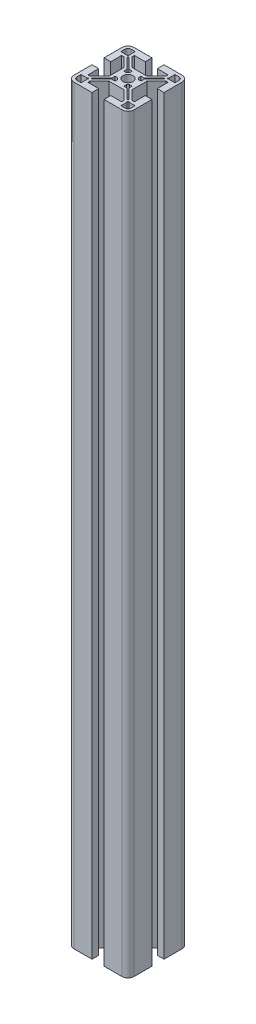
from build123d import *

# Parameters (mm, degrees)
BOSS_EXTRUDE1_DEPTH = 500


with BuildPart() as part:
    # Sketch1 → Boss-Extrude1 (new body)
    with BuildSketch(Plane(origin=(0, 0, 0), x_dir=(1, 0, 0), z_dir=(0, 1, 0))):
        with BuildLine():
            Line((-27.932618907, -6.859852703), (-27.932618907, 5.140147297))
            ThreePointArc((-27.932618907, 5.140147297), (-26.761046031, 7.968574422), (-23.932618907, 9.140147297))
            Line((-23.932618907, 9.140147297), (-11.932618907, 9.140147297))
            Line((-11.932618907, 9.140147297), (-11.932618907, 4.640147297))
            Line((-11.932618907, 4.640147297), (-19.182618907, 4.640147297))
            Line((-19.182618907, 4.640147297), (-19.182618907, 3.140147297))
            Line((-19.182618907, 3.140147297), (-12.932618907, -3.109852703))
            Line((-12.932618907, -3.109852703), (-7.932618907, -3.109852703))
            Line((-7.932618907, -3.109852703), (-2.932618907, -3.109852703))
            Line((-2.932618907, -3.109852703), (3.317381093, 3.140147297))
            Line((3.317381093, 3.140147297), (3.317381093, 4.640147297))
            Line((3.317381093, 4.640147297), (-3.932618907, 4.640147297))
            Line((-3.932618907, 4.640147297), (-3.932618907, 9.140147297))
            Line((-3.932618907, 9.140147297), (8.067381093, 9.140147297))
            ThreePointArc((8.067381093, 9.140147297), (10.895808218, 7.968574422), (12.067381093, 5.140147297))
            Line((12.067381093, 5.140147297), (12.067381093, -6.859852703))
            Line((12.067381093, -6.859852703), (7.567381093, -6.859852703))
            Line((7.567381093, -6.859852703), (7.567381093, 0.390147297))
            Line((7.567381093, 0.390147297), (6.067381093, 0.390147297))
            Line((6.067381093, 0.390147297), (-0.182618907, -5.859852703))
            Line((-0.182618907, -5.859852703), (-0.182618907, -10.859852703))
            Line((-0.182618907, -10.859852703), (-0.182618907, -15.859852703))
            Line((-0.182618907, -15.859852703), (6.067381093, -22.109852703))
            Line((6.067381093, -22.109852703), (7.567381093, -22.109852703))
            Line((7.567381093, -22.109852703), (7.567381093, -14.859852703))
            Line((7.567381093, -14.859852703), (12.067381093, -14.859852703))
            Line((12.067381093, -14.859852703), (12.067381093, -26.859852703))
            ThreePointArc((12.067381093, -26.859852703), (10.895808218, -29.688279827), (8.067381093, -30.859852703))
            Line((8.067381093, -30.859852703), (-3.932618907, -30.859852703))
            Line((-3.932618907, -30.859852703), (-3.932618907, -26.359852703))
            Line((-3.932618907, -26.359852703), (3.317381093, -26.359852703))
            Line((3.317381093, -26.359852703), (3.317381093, -24.859852703))
            Line((3.317381093, -24.859852703), (-2.932618907, -18.609852703))
            Line((-2.932618907, -18.609852703), (-7.932618907, -18.609852703))
            Line((-7.932618907, -18.609852703), (-12.932618907, -18.609852703))
            Line((-12.932618907, -18.609852703), (-19.182618907, -24.859852703))
            Line((-19.182618907, -24.859852703), (-19.182618907, -26.359852703))
            Line((-19.182618907, -26.359852703), (-11.932618907, -26.359852703))
            Line((-11.932618907, -26.359852703), (-11.932618907, -30.859852703))
            Line((-11.932618907, -30.859852703), (-23.932618907, -30.859852703))
            ThreePointArc((-23.932618907, -30.859852703), (-26.761046031, -29.688279827), (-27.932618907, -26.859852703))
            Line((-27.932618907, -26.859852703), (-27.932618907, -14.859852703))
            Line((-27.932618907, -14.859852703), (-23.432618907, -14.859852703))
            Line((-23.432618907, -14.859852703), (-23.432618907, -22.109852703))
            Line((-23.432618907, -22.109852703), (-21.932618907, -22.109852703))
            Line((-21.932618907, -22.109852703), (-15.682618907, -15.859852703))
            Line((-15.682618907, -15.859852703), (-15.682618907, -10.859852703))
            Line((-15.682618907, -10.859852703), (-15.682618907, -5.859852703))
            Line((-15.682618907, -5.859852703), (-21.932618907, 0.390147297))
            Line((-21.932618907, 0.390147297), (-23.432618907, 0.390147297))
            Line((-23.432618907, 0.390147297), (-23.432618907, -6.859852703))
            Line((-23.432618907, -6.859852703), (-27.932618907, -6.859852703))
        make_face()
        with BuildLine():
            Line((-25.932618907, 2.390147297), (-25.932618907, 5.140147297))
            ThreePointArc((-25.932618907, 5.140147297), (-25.346832469, 6.55436086), (-23.932618907, 7.140147297))
            Line((-23.932618907, 7.140147297), (-21.182618907, 7.140147297))
            Line((-21.182618907, 7.140147297), (-21.182618907, 3.097254079))
            Line((-21.182618907, 3.097254079), (-20.734395602, 2.649030774))
            Line((-20.734395602, 2.649030774), (-21.441502383, 1.941923993))
            Line((-21.441502383, 1.941923993), (-21.889725688, 2.390147297))
            Line((-21.889725688, 2.390147297), (-25.932618907, 2.390147297))
        make_face(mode=Mode.SUBTRACT)
        with BuildLine():
            Line((-20.380842211, 0.881263821), (-13.682618907, -5.816959484))
            Line((-13.682618907, -5.816959484), (-13.682618907, -7.955115193))
            Line((-13.682618907, -7.955115193), (-13.182618907, -7.955115193))
            Line((-13.182618907, -7.955115193), (-12.002324056, -7.955115193))
            ThreePointArc((-12.002324056, -7.955115193), (-11.468152813, -7.324318797), (-10.837356416, -6.790147554))
            Line((-10.837356416, -6.790147554), (-10.837356416, -5.609852703))
            Line((-10.837356416, -5.609852703), (-10.837356416, -5.109852703))
            Line((-10.837356416, -5.109852703), (-12.975512126, -5.109852703))
            Line((-12.975512126, -5.109852703), (-19.67373543, 1.588370602))
            Line((-19.67373543, 1.588370602), (-20.380842211, 0.881263821))
        make_face(mode=Mode.SUBTRACT)
        with BuildLine():
            Line((10.067381093, 2.390147297), (10.067381093, 5.140147297))
            ThreePointArc((10.067381093, 5.140147297), (9.481594656, 6.55436086), (8.067381093, 7.140147297))
            Line((8.067381093, 7.140147297), (5.317381093, 7.140147297))
            Line((5.317381093, 7.140147297), (5.317381093, 3.097254079))
            Line((5.317381093, 3.097254079), (4.869157789, 2.649030774))
            Line((4.869157789, 2.649030774), (5.57626457, 1.941923993))
            Line((5.57626457, 1.941923993), (6.024487874, 2.390147297))
            Line((6.024487874, 2.390147297), (10.067381093, 2.390147297))
        make_face(mode=Mode.SUBTRACT)
        with BuildLine():
            Line((-2.182618907, -5.816959484), (-2.182618907, -7.955115193))
            Line((-2.182618907, -7.955115193), (-2.682618907, -7.955115193))
            Line((-2.682618907, -7.955115193), (-3.862913758, -7.955115193))
            ThreePointArc((-3.862913758, -7.955115193), (-4.397085001, -7.324318797), (-5.027881397, -6.790147554))
            Line((-5.027881397, -6.790147554), (-5.027881397, -5.609852703))
            Line((-5.027881397, -5.609852703), (-5.027881397, -5.109852703))
            Line((-5.027881397, -5.109852703), (-2.889725688, -5.109852703))
            Line((-2.889725688, -5.109852703), (3.808497617, 1.588370602))
            Line((3.808497617, 1.588370602), (4.515604398, 0.881263821))
            Line((4.515604398, 0.881263821), (-2.182618907, -5.816959484))
        make_face(mode=Mode.SUBTRACT)
        with BuildLine():
            Line((5.317381093, -28.859852703), (8.067381093, -28.859852703))
            ThreePointArc((8.067381093, -28.859852703), (9.481594656, -28.274066265), (10.067381093, -26.859852703))
            Line((10.067381093, -26.859852703), (10.067381093, -24.109852703))
            Line((10.067381093, -24.109852703), (6.024487874, -24.109852703))
            Line((6.024487874, -24.109852703), (5.57626457, -23.661629398))
            Line((5.57626457, -23.661629398), (4.869157789, -24.368736179))
            Line((4.869157789, -24.368736179), (5.317381093, -24.816959484))
            Line((5.317381093, -24.816959484), (5.317381093, -28.859852703))
        make_face(mode=Mode.SUBTRACT)
        with BuildLine():
            Line((-2.889725688, -16.609852703), (-5.027881397, -16.609852703))
            Line((-5.027881397, -16.609852703), (-5.027881397, -16.109852703))
            Line((-5.027881397, -16.109852703), (-5.027881397, -14.929557852))
            ThreePointArc((-5.027881397, -14.929557852), (-4.397085001, -14.395386609), (-3.862913758, -13.764590212))
            Line((-3.862913758, -13.764590212), (-2.682618907, -13.764590212))
            Line((-2.682618907, -13.764590212), (-2.182618907, -13.764590212))
            Line((-2.182618907, -13.764590212), (-2.182618907, -15.902745921))
            Line((-2.182618907, -15.902745921), (4.515604398, -22.600969226))
            Line((4.515604398, -22.600969226), (3.808497617, -23.308076007))
            Line((3.808497617, -23.308076007), (-2.889725688, -16.609852703))
        make_face(mode=Mode.SUBTRACT)
        with BuildLine():
            Line((-25.932618907, -24.109852703), (-25.932618907, -26.859852703))
            ThreePointArc((-25.932618907, -26.859852703), (-25.346832469, -28.274066265), (-23.932618907, -28.859852703))
            Line((-23.932618907, -28.859852703), (-21.182618907, -28.859852703))
            Line((-21.182618907, -28.859852703), (-21.182618907, -24.816959484))
            Line((-21.182618907, -24.816959484), (-20.734395602, -24.368736179))
            Line((-20.734395602, -24.368736179), (-21.441502383, -23.661629398))
            Line((-21.441502383, -23.661629398), (-21.889725688, -24.109852703))
            Line((-21.889725688, -24.109852703), (-25.932618907, -24.109852703))
        make_face(mode=Mode.SUBTRACT)
        with BuildLine():
            Line((-13.682618907, -15.902745921), (-13.682618907, -13.764590212))
            Line((-13.682618907, -13.764590212), (-13.182618907, -13.764590212))
            Line((-13.182618907, -13.764590212), (-12.002324056, -13.764590212))
            ThreePointArc((-12.002324056, -13.764590212), (-11.468152813, -14.395386609), (-10.837356416, -14.929557852))
            Line((-10.837356416, -14.929557852), (-10.837356416, -16.109852703))
            Line((-10.837356416, -16.109852703), (-10.837356416, -16.609852703))
            Line((-10.837356416, -16.609852703), (-12.975512126, -16.609852703))
            Line((-12.975512126, -16.609852703), (-19.67373543, -23.308076007))
            Line((-19.67373543, -23.308076007), (-20.380842211, -22.600969226))
            Line((-20.380842211, -22.600969226), (-13.682618907, -15.902745921))
        make_face(mode=Mode.SUBTRACT)
        with BuildLine():
            ThreePointArc((-11.332618907, -10.859852703), (-10.336781963, -8.455689647), (-7.932618907, -7.459852703))
            ThreePointArc((-7.932618907, -7.459852703), (-5.528455851, -8.455689647), (-4.532618907, -10.859852703))
            ThreePointArc((-4.532618907, -10.859852703), (-5.528455851, -13.264015759), (-7.932618907, -14.259852703))
            ThreePointArc((-7.932618907, -14.259852703), (-10.336781963, -13.264015759), (-11.332618907, -10.859852703))
        make_face(mode=Mode.SUBTRACT)
    extrude(amount=BOSS_EXTRUDE1_DEPTH)


solid = part.part
